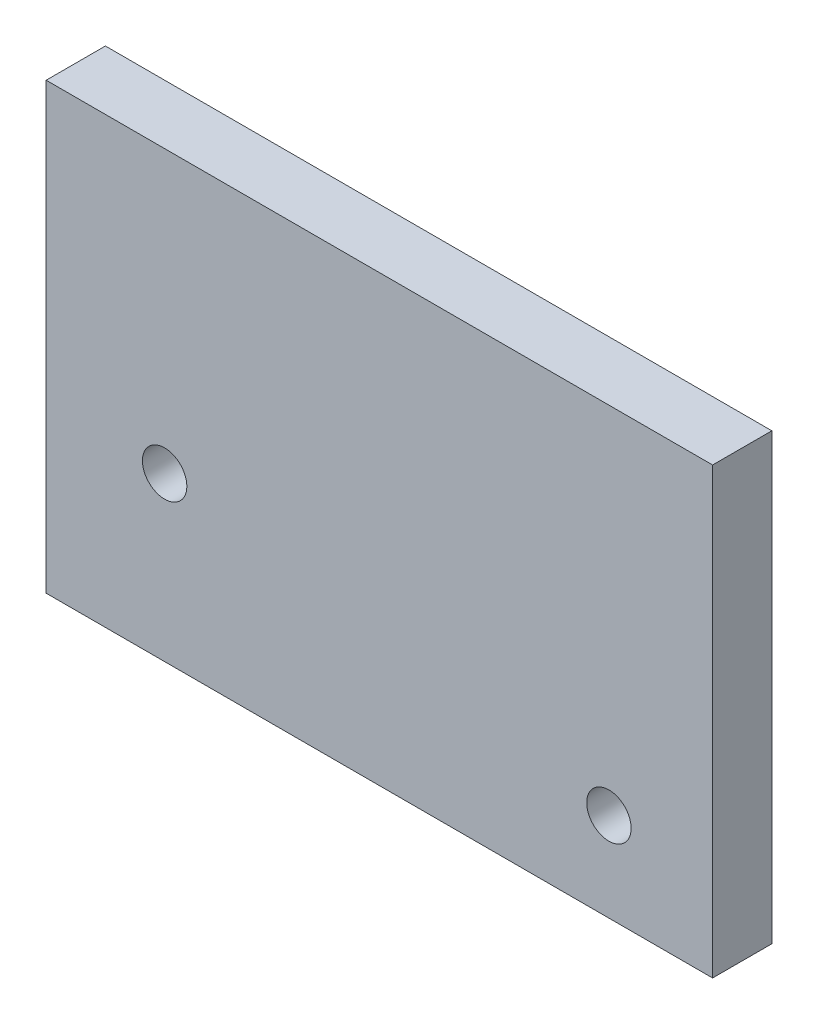
from build123d import *

# Parameters (mm, degrees)
SKETCH1_W           = 45
SKETCH1_H           = 30
SKETCH1_R           = 1.5
BOSS_EXTRUDE1_DEPTH = 4


with BuildPart() as part:
    # Sketch1 → Boss-Extrude1 (new body)
    with BuildSketch(Plane.XY):
        with Locations((22.5, 15)):
            Rectangle(SKETCH1_W, SKETCH1_H)
        with Locations((38, 6)):
            Circle(SKETCH1_R, mode=Mode.SUBTRACT)
        with Locations((8, 11)):
            Circle(SKETCH1_R, mode=Mode.SUBTRACT)
    extrude(amount=BOSS_EXTRUDE1_DEPTH)


solid = part.part
